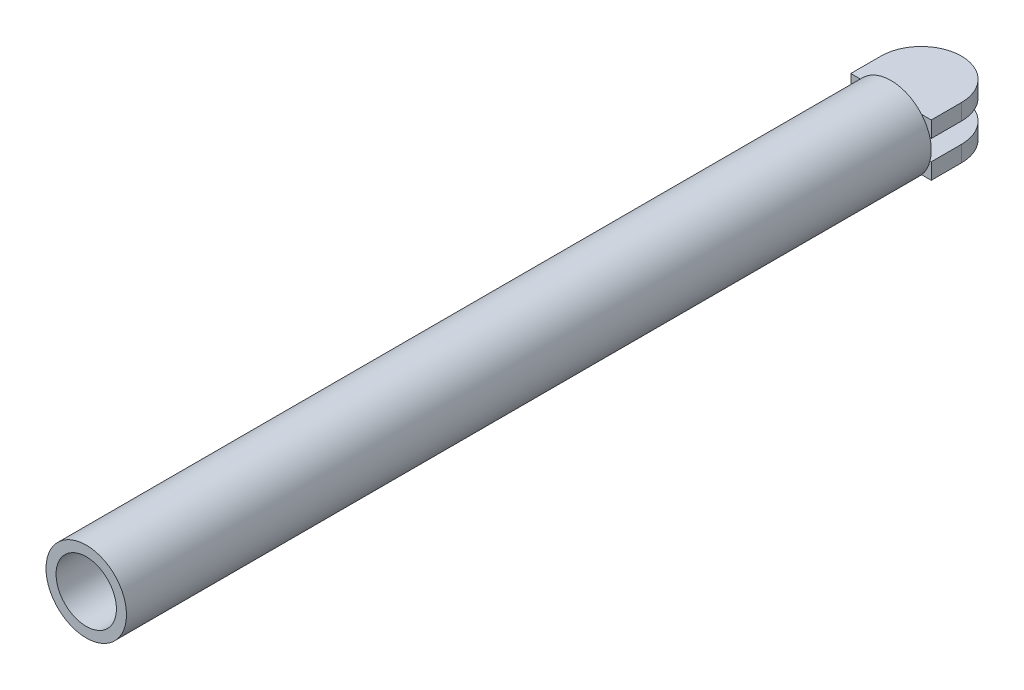
from build123d import *

# Parameters (mm, degrees)
SKETCH1_R           = 20
SKETCH1_R_2         = 15
BOSS_EXTRUDE1_DEPTH = 200
BOSS_EXTRUDE5_START = 5
BOSS_EXTRUDE5_DEPTH = 8
BOSS_EXTRUDE6_START = -13
BOSS_EXTRUDE6_DEPTH = 8
BOSS_EXTRUDE7_START = -8
SKETCH7_R           = 3.5
BOSS_EXTRUDE7_DEPTH = 10


with BuildPart() as part:
    # Sketch1 → Boss-Extrude1 (new, symmetric)
    with BuildSketch(Plane.XY):
        Circle(SKETCH1_R)
        Circle(SKETCH1_R_2, mode=Mode.SUBTRACT)
    extrude(amount=BOSS_EXTRUDE1_DEPTH, both=True)

    # Sketch6 → Boss-Extrude5 (add)
    with BuildSketch(Plane(origin=(0, 0, 0), x_dir=(1, 0, 0), z_dir=(0, 1, 0)).offset(BOSS_EXTRUDE5_START)):
        with BuildLine():
            Line((-20, 200), (20, 200))
            Line((20, 200), (20, 215))
            ThreePointArc((20, 215), (0, 235), (-20, 215))
            Line((-20, 215), (-20, 200))
        make_face()
    extrude(amount=BOSS_EXTRUDE5_DEPTH)

    # Sketch6_2 → Boss-Extrude6 (add)
    with BuildSketch(Plane(origin=(0, 0, 0), x_dir=(1, 0, 0), z_dir=(0, 1, 0)).offset(BOSS_EXTRUDE6_START)):
        with BuildLine():
            Line((-20, 200), (20, 200))
            Line((20, 200), (20, 215))
            ThreePointArc((20, 215), (0, 235), (-20, 215))
            Line((-20, 215), (-20, 200))
        make_face()
    extrude(amount=BOSS_EXTRUDE6_DEPTH)

    # Sketch7 → Boss-Extrude7 (add)
    with BuildSketch(Plane.XZ.offset(13).offset(BOSS_EXTRUDE7_START)):
        with Locations((0, -215)):
            Circle(SKETCH7_R)
    extrude(amount=-BOSS_EXTRUDE7_DEPTH)


solid = part.part
